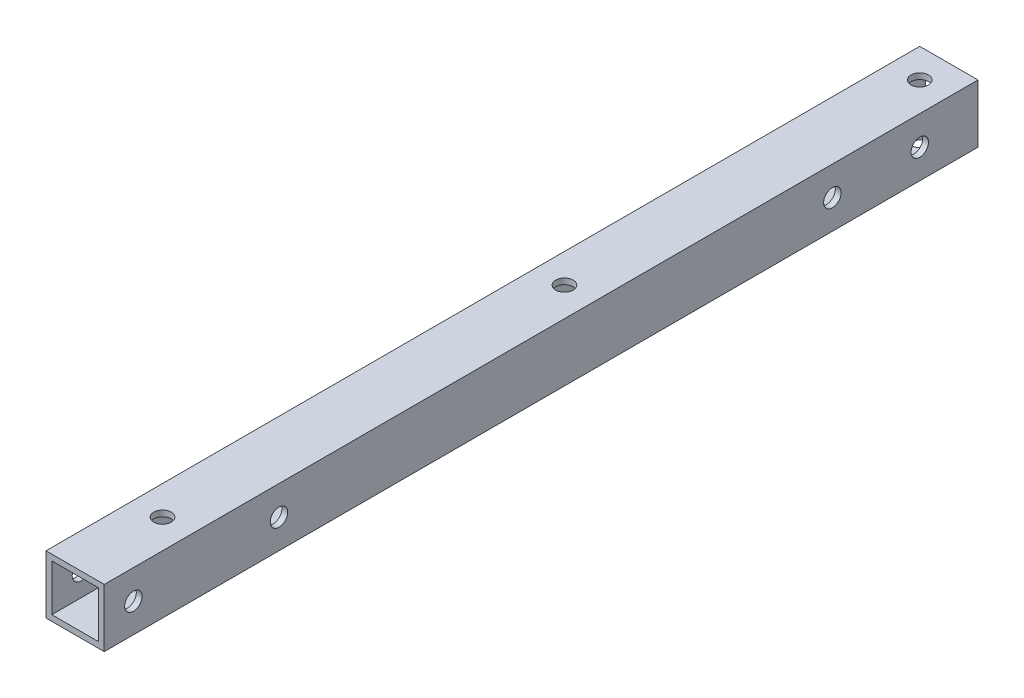
from build123d import *

# Parameters (mm, degrees)
SKETCH_1_W          = 10
SKETCH_1_H          = 10
SKETCH_1_W_2        = 8
SKETCH_1_H_2        = 8
EXTRUDE_1_DEPTH     = 150
SKETCH_2_R          = 1.5
CUT_EXTRUDE_1_DEPTH = 11
SKETCH_3_R          = 1.5
CUT_EXTRUDE_2_DEPTH = 11


with BuildPart() as part:
    # 草图1 → 拉伸-薄壁1 (new body)
    with BuildSketch(Plane.XY):
        with Locations((4.161089293, -159.112745336)):
            Rectangle(SKETCH_1_W, SKETCH_1_H)
        with Locations((4.161089293, -159.112745336)):
            Rectangle(SKETCH_1_W_2, SKETCH_1_H_2, mode=Mode.SUBTRACT)
    extrude(amount=EXTRUDE_1_DEPTH)

    # 草图2 → 切除-拉伸1 (cut, through all)
    with BuildSketch(Plane.XZ.offset(164.112745336)):
        with Locations((4.161089293, 135)):
            Circle(SKETCH_2_R)
        with Locations((4.161089293, 66)):
            Circle(SKETCH_2_R)
        with Locations((4.161089293, 5)):
            Circle(SKETCH_2_R)
    extrude(amount=-CUT_EXTRUDE_1_DEPTH, mode=Mode.SUBTRACT)

    # 草图3 → 切除-拉伸2 (cut, through all)
    with BuildSketch(Plane(origin=(9.161089293, 0, 0), x_dir=(0, 0, -1), z_dir=(1, 0, 0))):
        with Locations((-25, -159.112745336)):
            Circle(SKETCH_3_R)
        with Locations((-10, -159.112745336)):
            Circle(SKETCH_3_R)
        with Locations((-120, -159.112745336)):
            Circle(SKETCH_3_R)
        with Locations((-145, -159.112745336)):
            Circle(SKETCH_3_R)
    extrude(amount=-CUT_EXTRUDE_2_DEPTH, mode=Mode.SUBTRACT)


solid = part.part
